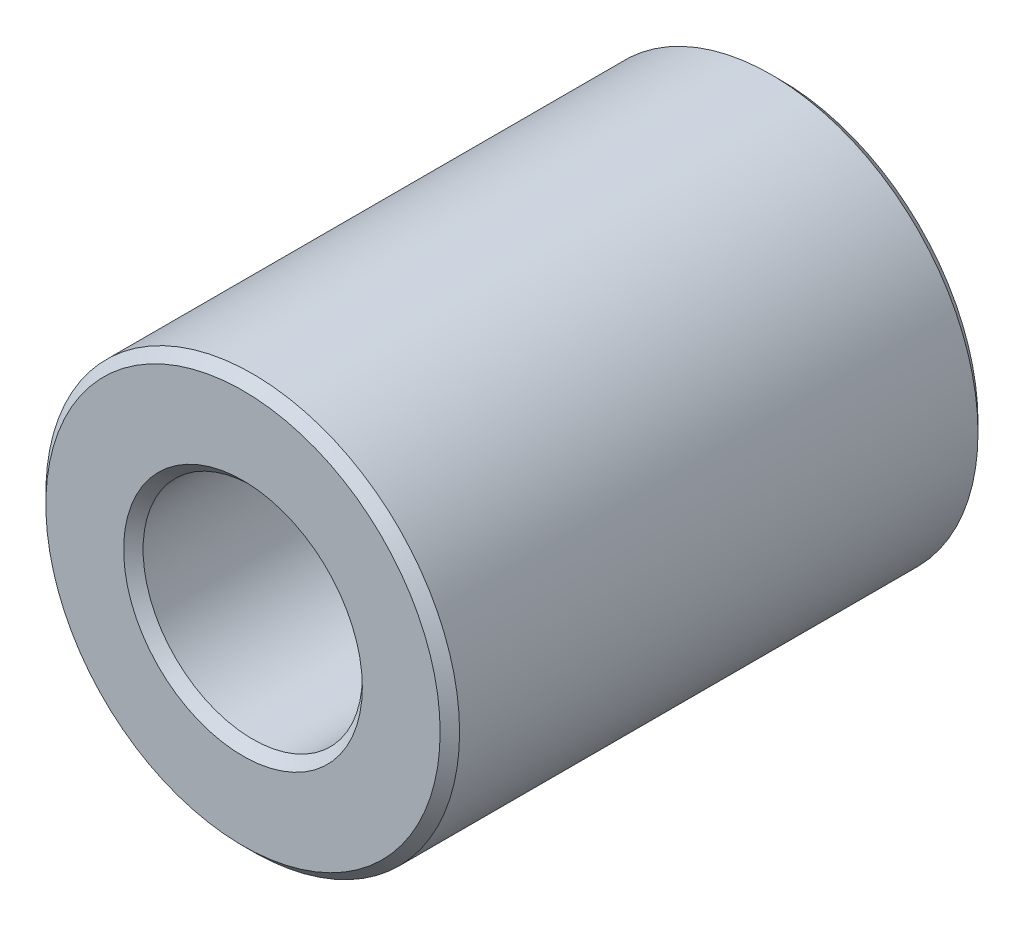
from build123d import *

# Parameters (mm, degrees)
BOSS_EXTRUDE1_DEPTH      = 6.5
BOSS_EXTRUDE1_DEPTH_BACK = 6.5
SKETCH3_R                = 5
SKETCH3_R_2              = 2.65
CHAMFER1_SIZE            = 0.235


with BuildPart() as part:
    # Sketch3 → Boss-Extrude1 (new, two sides: drawn at the far end of the back side and taken through both)
    with BuildSketch(Plane.XY.offset(-BOSS_EXTRUDE1_DEPTH_BACK)):
        Circle(SKETCH3_R)
        Circle(SKETCH3_R_2, mode=Mode.SUBTRACT)
    extrude(amount=BOSS_EXTRUDE1_DEPTH + BOSS_EXTRUDE1_DEPTH_BACK)

    # Chamfer1
    chamfer1_edges = [part.edges().sort_by_distance(p)[0] for p in [
        (-5, 0, -6.5),
        (-2.65, 0, -6.5),
        (-5, 0, 6.5),
        (-2.65, 0, 6.5),
    ]]
    chamfer(chamfer1_edges, length=CHAMFER1_SIZE)


solid = part.part
